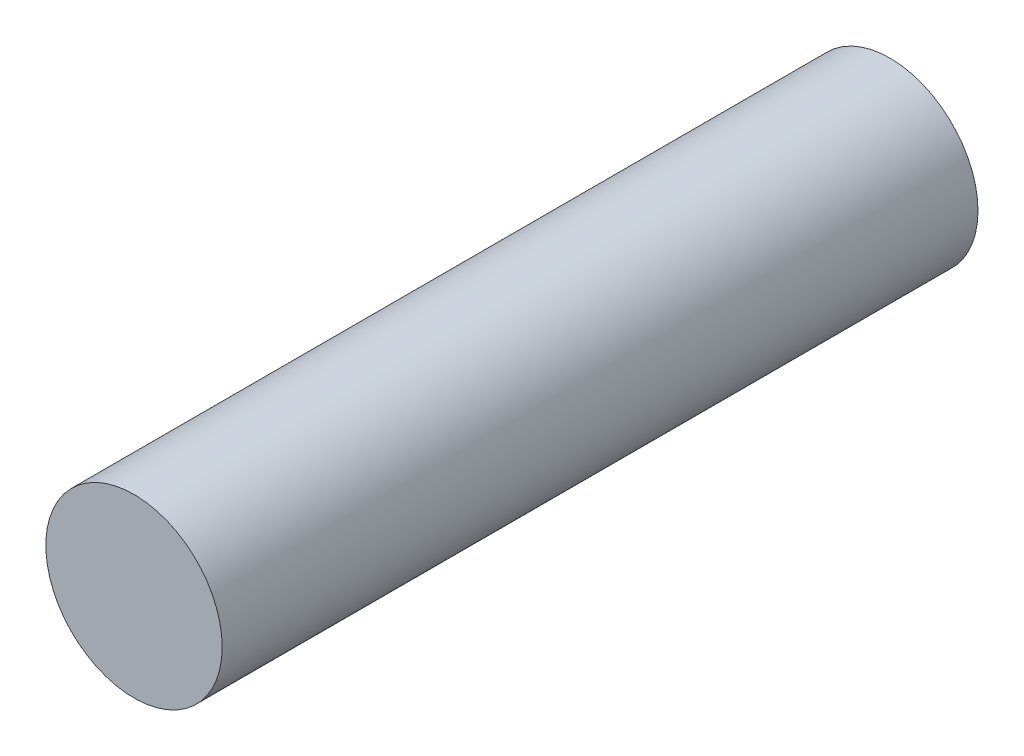
from build123d import *

# Parameters (mm, degrees)
SKIZZE1_R                       = 2.1
AUFSATZ_LINEAR_AUSTRAGEN1_DEPTH = 18


with BuildPart() as part:
    # Skizze1 → Aufsatz-Linear austragen1 (new body)
    with BuildSketch(Plane.XY):
        Circle(SKIZZE1_R)
    extrude(amount=AUFSATZ_LINEAR_AUSTRAGEN1_DEPTH)


solid = part.part
